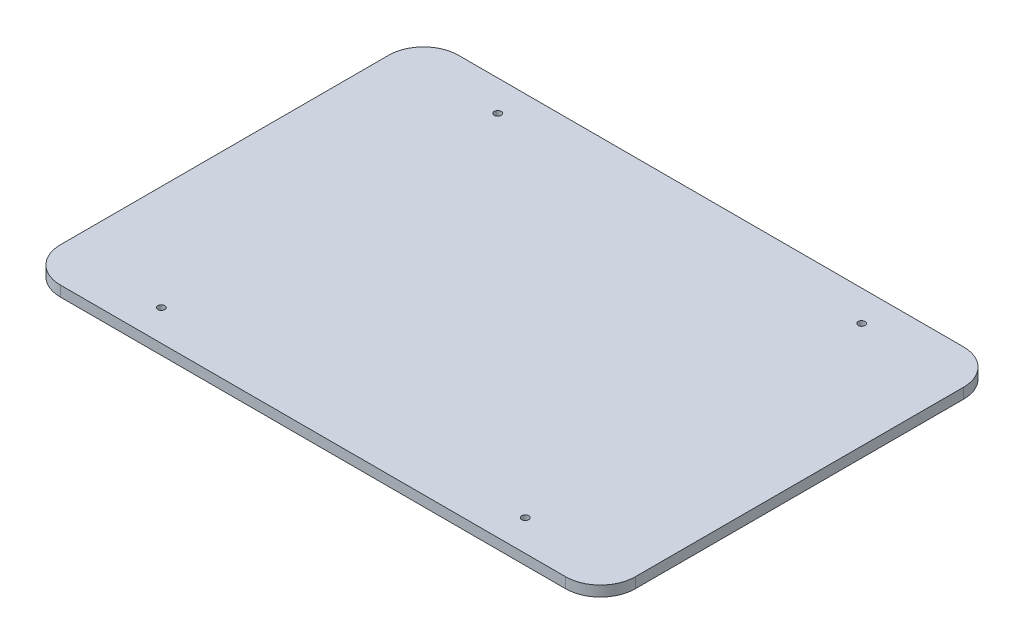
from build123d import *

# Parameters (mm, degrees)
SKETCH1_W           = 165.1
SKETCH1_H           = 114.3
BOSS_EXTRUDE1_DEPTH = 3
FILLET1_R           = 10
SKETCH2_R           = 1
CUT_EXTRUDE1_DEPTH  = 4


with BuildPart() as part:
    # Sketch1 → Boss-Extrude1 (new body)
    with BuildSketch(Plane(origin=(0, 0, 0), x_dir=(1, 0, 0), z_dir=(0, 1, 0))):
        Rectangle(SKETCH1_W, SKETCH1_H)
    extrude(amount=BOSS_EXTRUDE1_DEPTH)

    # Fillet1
    fillet1_edges = [part.edges().sort_by_distance(p)[0] for p in [
        (82.55, 1.5, 57.15),
        (-82.55, 1.5, 57.15),
        (-82.55, 1.5, -57.15),
        (82.55, 1.5, -57.15),
    ]]
    fillet(fillet1_edges, radius=FILLET1_R)

    # Sketch2 → Cut-Extrude1 (cut, through all)
    with BuildSketch(Plane.XZ):
        with Locations((-52.43, 48.26)):
            Circle(SKETCH2_R)
        with Locations((-52.43, -48.34)):
            Circle(SKETCH2_R)
        with Locations((52.07, 48.26)):
            Circle(SKETCH2_R)
        with Locations((52.07, -48.34)):
            Circle(SKETCH2_R)
    extrude(amount=-CUT_EXTRUDE1_DEPTH, mode=Mode.SUBTRACT)


solid = part.part
